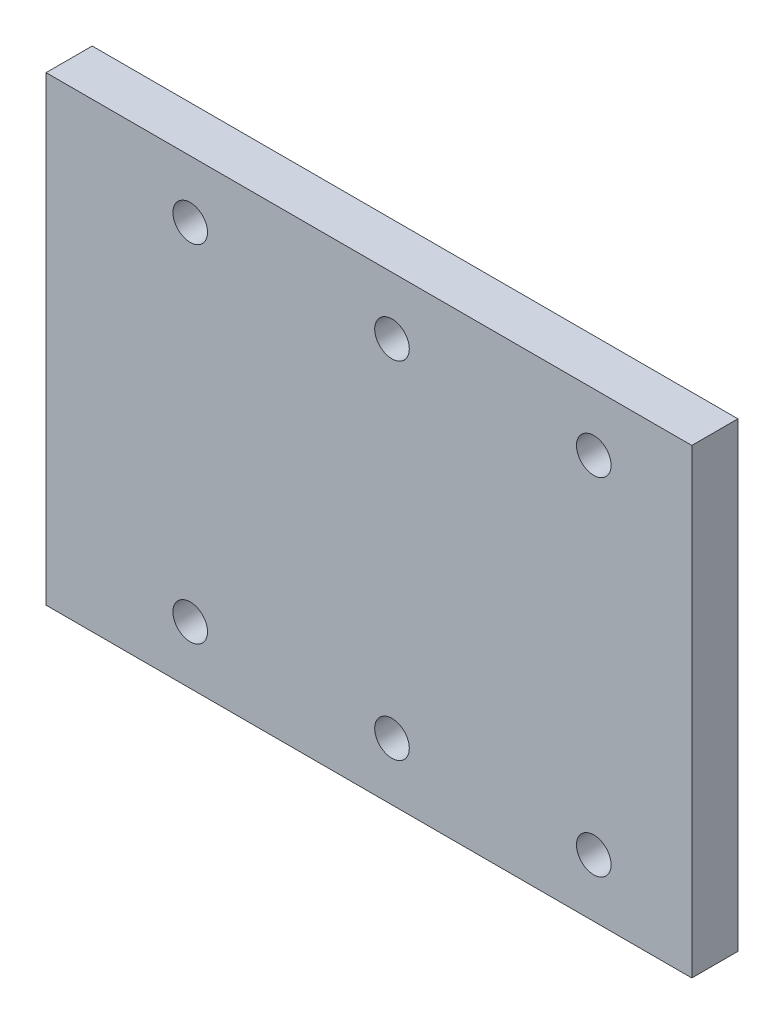
from build123d import *

# Parameters (mm, degrees)
SKETCH1_W           = 56
SKETCH1_H           = 40
BOSS_EXTRUDE1_DEPTH = 4
SKETCH3_W           = 56
SKETCH3_H           = 3
CUT_EXTRUDE2_DEPTH  = 2
SKETCH4_R           = 1.5
CUT_EXTRUDE3_DEPTH  = 5
SKETCH5_W           = 56
SKETCH5_H           = 3
BOSS_EXTRUDE2_DEPTH = 2


with BuildPart() as part:
    # Sketch1 → Boss-Extrude1 (new body)
    with BuildSketch(Plane.XY):
        with Locations((28, 20)):
            Rectangle(SKETCH1_W, SKETCH1_H)
    extrude(amount=BOSS_EXTRUDE1_DEPTH)

    # Sketch3 → Cut-Extrude2 (cut)
    with BuildSketch(Plane.XY.offset(4)):
        with Locations((28, 1.5)):
            Rectangle(SKETCH3_W, SKETCH3_H)
    extrude(amount=-CUT_EXTRUDE2_DEPTH, mode=Mode.SUBTRACT)

    # Sketch4 → Cut-Extrude3 (cut, through all)
    with BuildSketch(Plane.XY.offset(4)):
        with Locations((47.5, 5)):
            Circle(SKETCH4_R)
        with Locations((30, 5)):
            Circle(SKETCH4_R)
        with Locations((12.5, 5)):
            Circle(SKETCH4_R)
        with Locations((47.5, 35)):
            Circle(SKETCH4_R)
        with Locations((30, 35)):
            Circle(SKETCH4_R)
        with Locations((12.5, 35)):
            Circle(SKETCH4_R)
    extrude(amount=-CUT_EXTRUDE3_DEPTH, mode=Mode.SUBTRACT)

    # Sketch5 → Boss-Extrude2 (add)
    with BuildSketch(Plane.XY.offset(4)):
        with Locations((28, 1.5)):
            Rectangle(SKETCH5_W, SKETCH5_H)
    extrude(amount=-BOSS_EXTRUDE2_DEPTH)


solid = part.part
